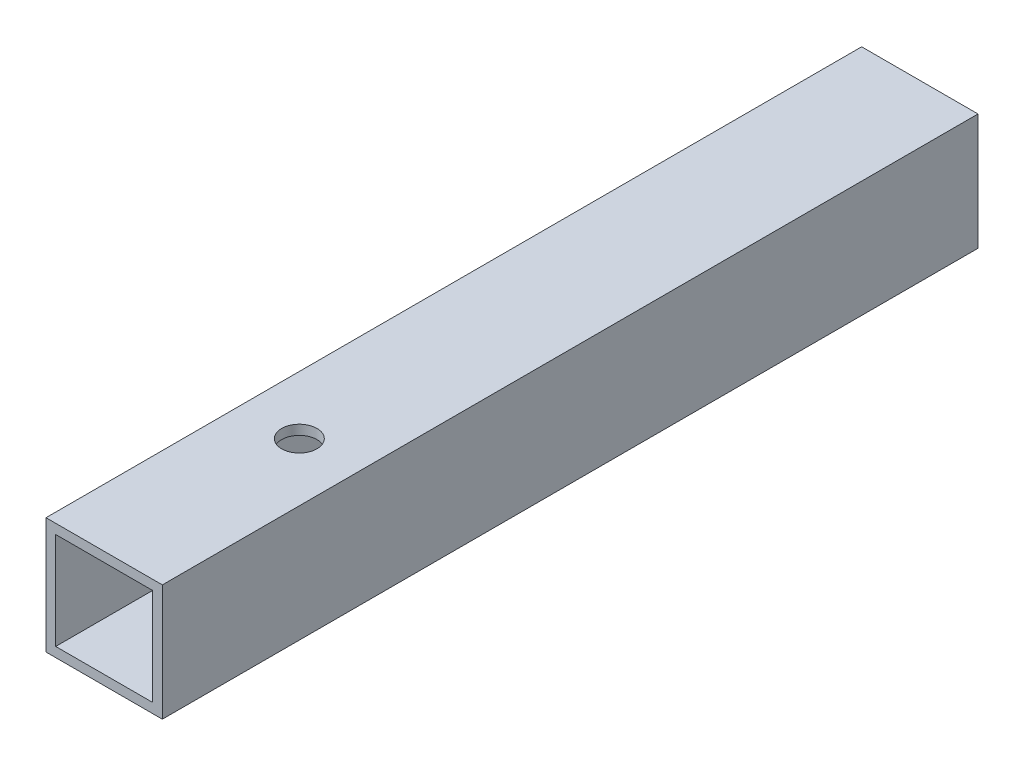
from build123d import *

# Parameters (mm, degrees)
SKETCH1_W                = 19.05
SKETCH1_H                = 19.05
SKETCH1_W_2              = 15.875
SKETCH1_H_2              = 15.875
BOSS_EXTRUDE1_DEPTH      = 66.7766
SKETCH2_R                = 2.8956
BASEPLATEMOUNTHOLE_DEPTH = 20.05
CUT_EXTRUDE1_REACH       = 21.05
SKETCH3_R                = 4.7625


with BuildPart() as part:
    # Sketch1 → Boss-Extrude1 (new body, symmetric)
    with BuildSketch(Plane(origin=(0, 0, 0), x_dir=(0, -1, 0), z_dir=(0, 0, 1))):
        Rectangle(SKETCH1_W, SKETCH1_H)
        Rectangle(SKETCH1_W_2, SKETCH1_H_2, mode=Mode.SUBTRACT)
    extrude(amount=BOSS_EXTRUDE1_DEPTH, both=True)

    # Sketch2 → BasePlateMountHole (cut, through all)
    with BuildSketch(Plane(origin=(0, 9.525, 0), x_dir=(1, 0, 0), z_dir=(0, 1, 0))):
        with Locations((0, -34.8234)):
            Circle(SKETCH2_R)
    extrude(amount=-BASEPLATEMOUNTHOLE_DEPTH, mode=Mode.SUBTRACT)

    # Sketch3 → Cut-Extrude1 (cut, up to next)
    with BuildSketch(Plane.ZY.offset(9.525), mode=Mode.PRIVATE) as cut_extrude1_sk1:
        with Locations((3.3782, 0)):
            Circle(SKETCH3_R)
    cut_extrude1_tool1 = extrude(cut_extrude1_sk1.sketch, amount=-CUT_EXTRUDE1_REACH, mode=Mode.PRIVATE) & part.part
    add(cut_extrude1_tool1.solids().sort_by_distance((-9.525, 0, 3.3782))[0], mode=Mode.SUBTRACT)


solid = part.part
